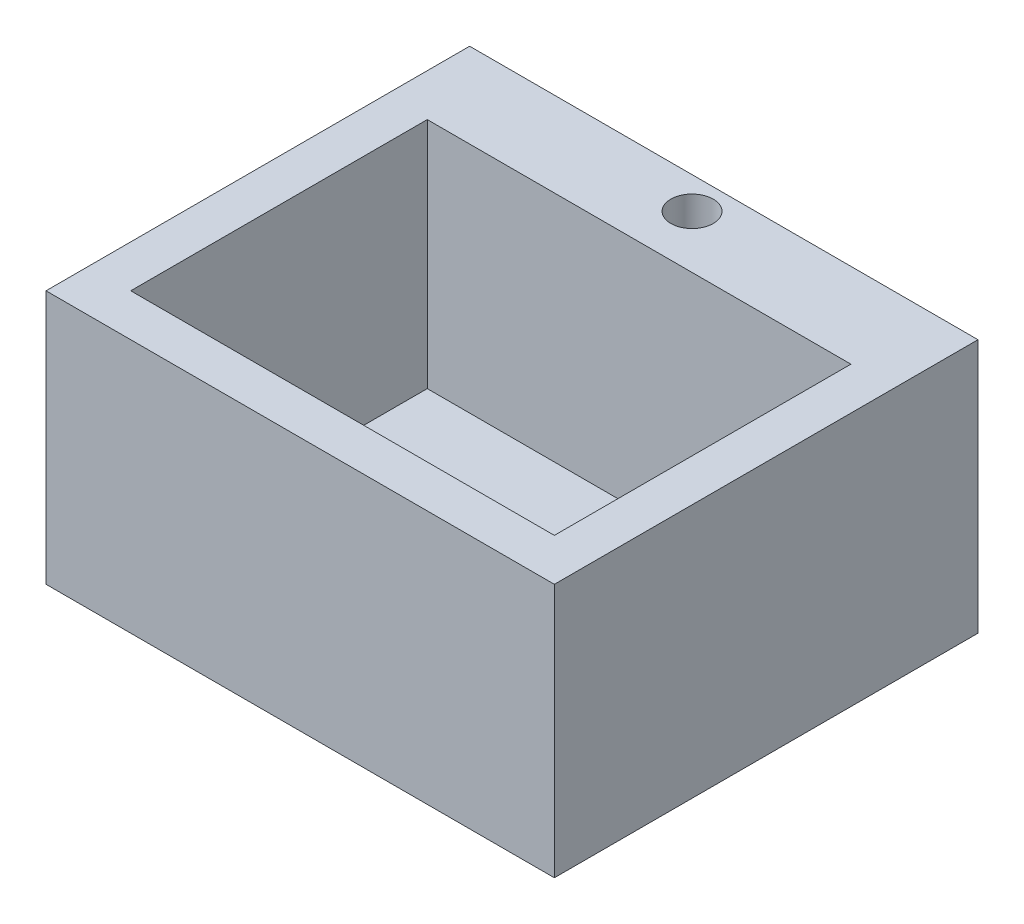
from build123d import *

# Parameters (mm, degrees)
SKETCH1_W           = 304.8
SKETCH1_H           = 254
SKETCH1_R           = 19.05
SKETCH1_R_2         = 12.7
BOSS_EXTRUDE1_DEPTH = 152.4
SKETCH2_W           = 254
SKETCH2_H           = 177.8
CUT_EXTRUDE1_DEPTH  = 139.7


with BuildPart() as part:
    # Sketch1 → Boss-Extrude1 (new body)
    with BuildSketch(Plane(origin=(0, 0, 0), x_dir=(1, 0, 0), z_dir=(0, 1, 0))):
        with Locations((22.344281622, -62.278846154)):
            Rectangle(SKETCH1_W, SKETCH1_H)
        with Locations((22.344281622, -81.328846154)):
            Circle(SKETCH1_R, mode=Mode.SUBTRACT)
        with Locations((22.344281622, 45.671153846)):
            Circle(SKETCH1_R_2, mode=Mode.SUBTRACT)
    extrude(amount=-BOSS_EXTRUDE1_DEPTH)

    # Sketch2 → Cut-Extrude1 (cut)
    with BuildSketch(Plane(origin=(0, 0, 0), x_dir=(1, 0, 0), z_dir=(0, 1, 0))):
        with Locations((22.344281622, -74.978846154)):
            Rectangle(SKETCH2_W, SKETCH2_H)
    extrude(amount=-CUT_EXTRUDE1_DEPTH, mode=Mode.SUBTRACT)


solid = part.part
